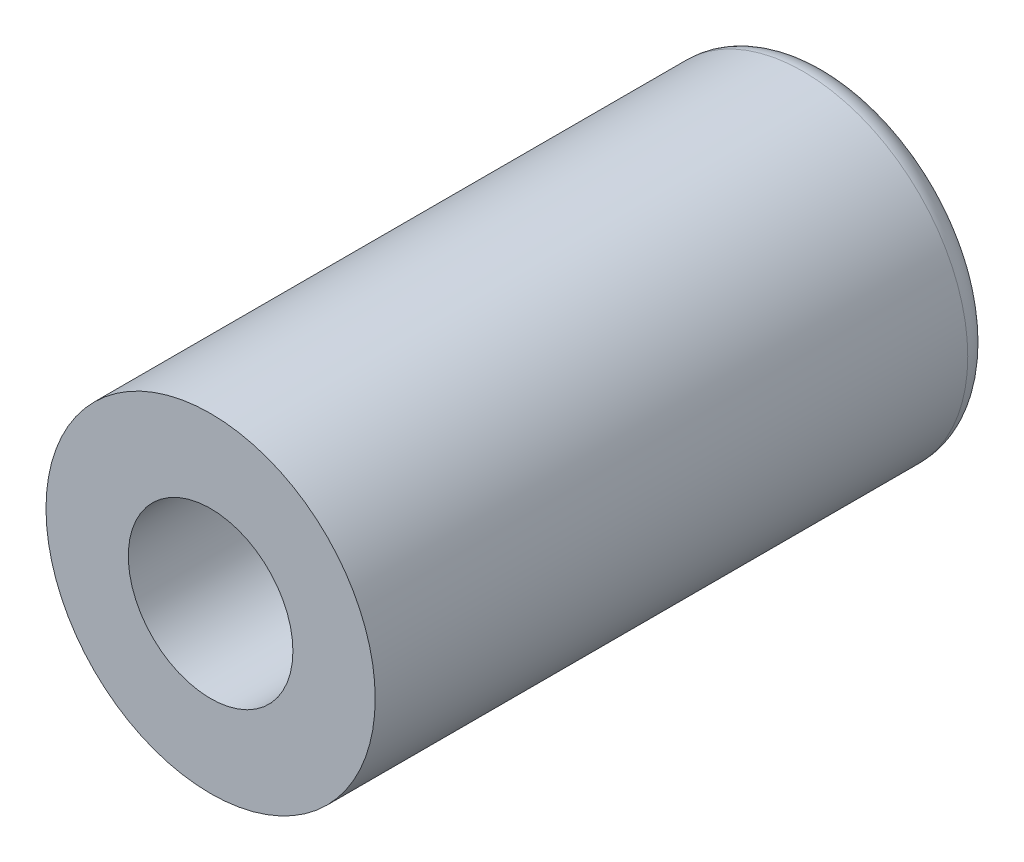
from build123d import *

# Parameters (mm, degrees)
SKETCH1_R           = 4
BOSS_EXTRUDE1_DEPTH = 15
SKETCH2_R           = 2
CUT_EXTRUDE1_DEPTH  = 13
FILLET1_R           = 0.6


with BuildPart() as part:
    # Sketch1 → Boss-Extrude1 (new body)
    with BuildSketch(Plane.XY):
        Circle(SKETCH1_R)
    extrude(amount=BOSS_EXTRUDE1_DEPTH)

    # Sketch2 → Cut-Extrude1 (cut)
    with BuildSketch(Plane.XY.offset(15)):
        Circle(SKETCH2_R)
    extrude(amount=-CUT_EXTRUDE1_DEPTH, mode=Mode.SUBTRACT)

    # Fillet1
    fillet1_edges = [part.edges().sort_by_distance(p)[0] for p in [
        (-4, 0, 0),
    ]]
    fillet(fillet1_edges, radius=FILLET1_R)


solid = part.part
